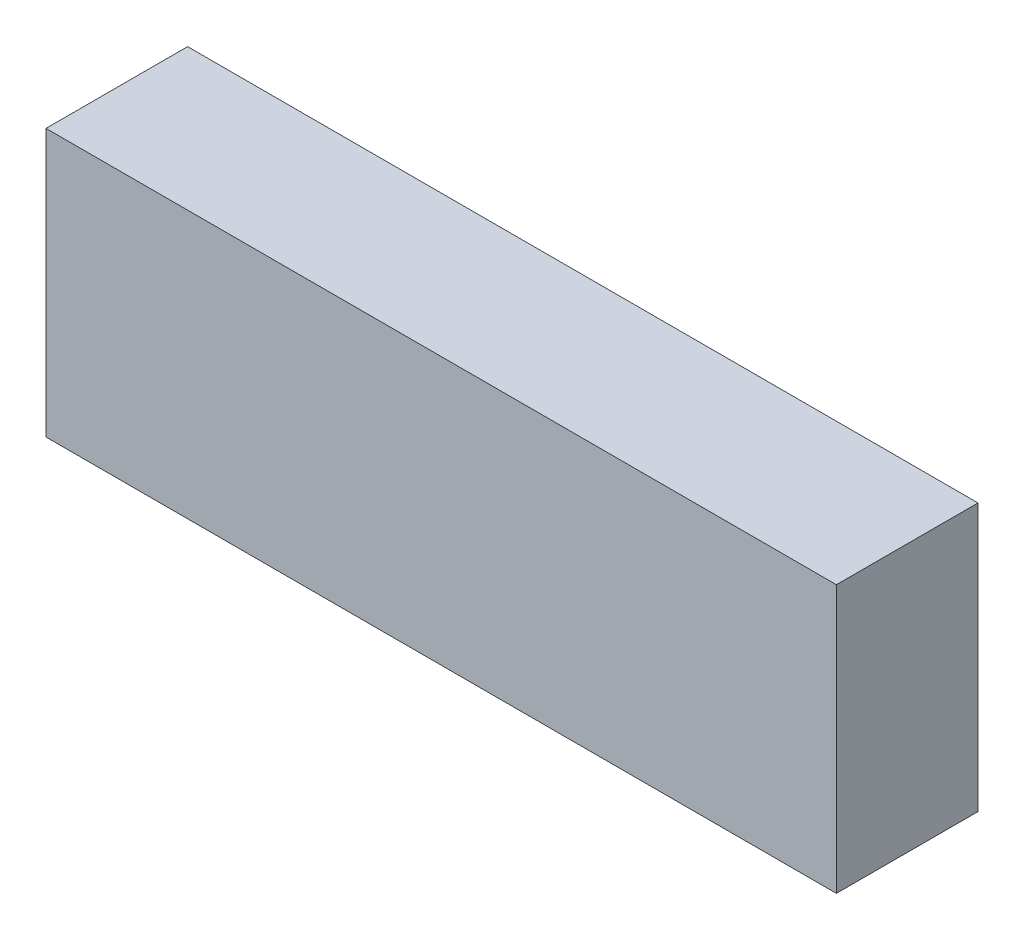
from build123d import *

# Parameters (mm, degrees)
SKETCH1_W           = 138.938
SKETCH1_H           = 46.99
BOSS_EXTRUDE1_DEPTH = 24.892


with BuildPart() as part:
    # Sketch1 → Boss-Extrude1 (new body)
    with BuildSketch(Plane.XY):
        Rectangle(SKETCH1_W, SKETCH1_H)
    extrude(amount=BOSS_EXTRUDE1_DEPTH)


solid = part.part
